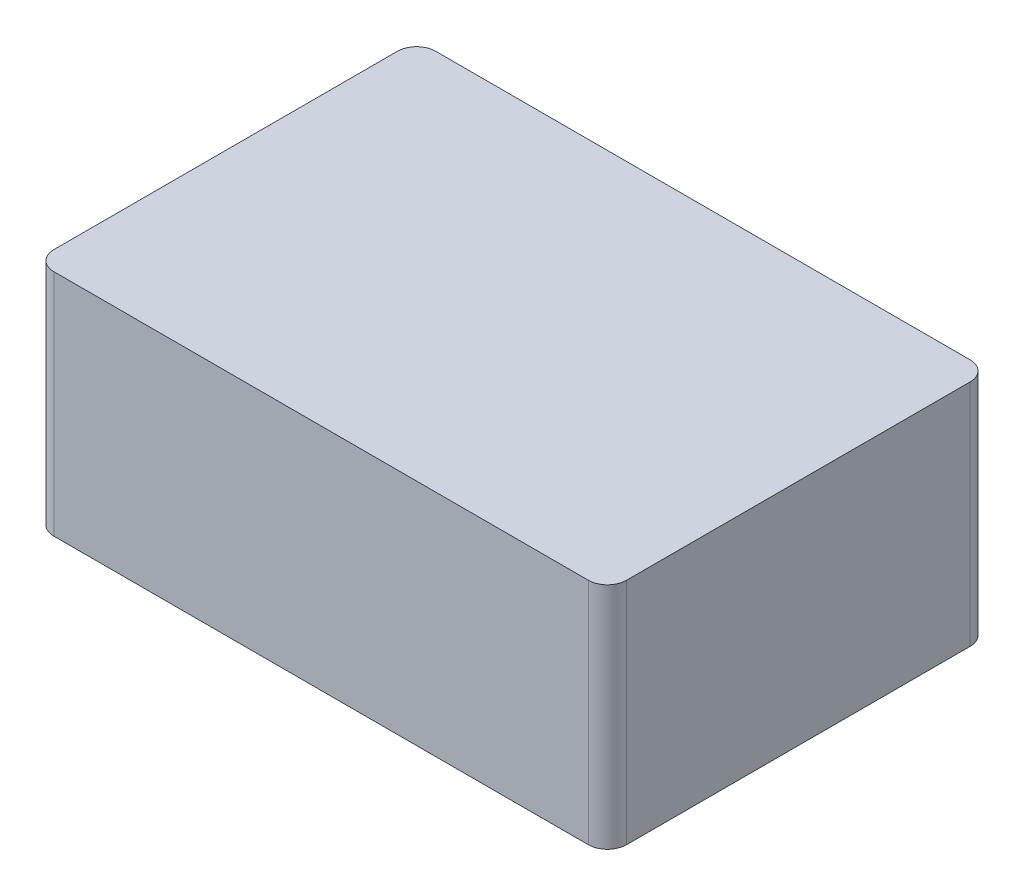
from build123d import *

# Parameters (mm, degrees)
SKETCH1_W               = 150
SKETCH1_H               = 100
BOSS_EXTRUDE1_DEPTH     = 60
SHELL1_T                = -3
SKETCH2_W               = 4
SKETCH2_H               = 4
BOSS_EXTRUDE2_DEPTH     = 20
SKETCH3_R               = 0.85
CUT_EXTRUDE1_DEPTH      = 10
SKETCH4_W               = 51
SKETCH4_H               = 28.5
BOSS_EXTRUDE3_DEPTH     = 57
SKETCH5_W               = 49
SKETCH5_H               = 26.5
CUT_EXTRUDE2_DEPTH      = 17.5
SKETCH6_W               = 7.316020892
SKETCH6_H               = 10.063527081
SKETCH6_W_2             = 9.991581276
SKETCH6_H_2             = 9.876768552
CUT_EXTRUDE3_DEPTH      = 1
RIB1_REACH              = 188.304
SKETCH7_WALLS_W         = 497.226705155
SKETCH7_WALLS_H         = 2
SKETCH7_WALLS_W_2       = 2
SKETCH7_WALLS_H_2       = 447.528019614
SKETCH7_WALLS_H_3       = 446.492630332
SKETCH7_WALLS_H_4       = 428.743099781
SKETCH7_WALLS_W_3       = 498.853745456
SKETCH8_W               = 7
SKETCH8_H               = 7
BOSS_EXTRUDE4_DEPTH     = 57
MIRROR2_COPY_1_SKETCH_W = 7
MIRROR2_COPY_1_SKETCH_H = 7
MIRROR2_COPY_1_DEPTH    = 57
SKETCH9_R               = 2
CUT_EXTRUDE4_DEPTH      = 10
MIRROR4_COPY_1_SKETCH_R = 2
MIRROR4_COPY_1_DEPTH    = 10
FILLET1_R               = 5


with BuildPart() as part:
    # Sketch1 → Boss-Extrude1 (new body)
    with BuildSketch(Plane(origin=(0, 0, 0), x_dir=(1, 0, 0), z_dir=(0, 1, 0))):
        with Locations((75, 50)):
            Rectangle(SKETCH1_W, SKETCH1_H)
    extrude(amount=BOSS_EXTRUDE1_DEPTH)

    # Shell1
    shell1_openings = [part.faces().sort_by_distance(p)[0] for p in [
        (75, 0, -50),
    ]]
    offset(amount=SHELL1_T, openings=shell1_openings, kind=Kind.INTERSECTION)

    # Sketch2 → Boss-Extrude2 (add)
    with BuildSketch(Plane.XZ.offset(-57)):
        with Locations((20, -90)):
            Rectangle(SKETCH2_W, SKETCH2_H)
        with Locations((64.26, -90)):
            Rectangle(SKETCH2_W, SKETCH2_H)
        with Locations((20, -38.12)):
            Rectangle(SKETCH2_W, SKETCH2_H)
        with Locations((64.26, -38.12)):
            Rectangle(SKETCH2_W, SKETCH2_H)
    extrude(amount=BOSS_EXTRUDE2_DEPTH)

    # Sketch3 → Cut-Extrude1 (cut)
    with BuildSketch(Plane.XZ.offset(-37)):
        with Locations(Location((20.3, -89.7, 0), (0, 0, 270))):
            Circle(SKETCH3_R)
        with Locations(Location((20.3, -38.42, 0), (0, 0, 270))):
            Circle(SKETCH3_R)
        with Locations(Location((63.96, -38.42, 0), (0, 0, 270))):
            Circle(SKETCH3_R)
        with Locations(Location((63.96, -89.7, 0), (0, 0, 270))):
            Circle(SKETCH3_R)
    extrude(amount=-CUT_EXTRUDE1_DEPTH, mode=Mode.SUBTRACT)

    # Sketch4 → Boss-Extrude3 (add)
    with BuildSketch(Plane.XZ.offset(-57)):
        with Locations((45.5, -20.25)):
            Rectangle(SKETCH4_W, SKETCH4_H)
    extrude(amount=BOSS_EXTRUDE3_DEPTH)

    # Sketch5 → Cut-Extrude2 (cut)
    with BuildSketch(Plane.XZ):
        with Locations((45.5, -20.25)):
            Rectangle(SKETCH5_W, SKETCH5_H)
    extrude(amount=-CUT_EXTRUDE2_DEPTH, mode=Mode.SUBTRACT)

    # Sketch6 → Cut-Extrude3 (cut)
    with BuildSketch(Plane(origin=(71, 0, 0), x_dir=(0, 0, -1), z_dir=(1, 0, 0))):
        with Locations((27.946274495, 5.031763541)):
            Rectangle(SKETCH6_W, SKETCH6_H)
        with Locations((13.255259514, 4.938384276)):
            Rectangle(SKETCH6_W_2, SKETCH6_H_2)
    extrude(amount=-CUT_EXTRUDE3_DEPTH, mode=Mode.SUBTRACT)

    # Sketch7 walls → Rib1 (add, up to next)
    with BuildSketch(Plane(origin=(0, 47, 0), x_dir=(-1, 0, 0), z_dir=(0, -1, 0)), mode=Mode.PRIVATE) as rib1_sk1:
        with Locations((-74.334392604, 80.691896577)):
            Rectangle(SKETCH7_WALLS_W, SKETCH7_WALLS_H)
    rib1_tool1 = extrude(rib1_sk1.sketch, amount=-RIB1_REACH, mode=Mode.PRIVATE) - part.part
    # Sketch7 walls → Rib1 (add, up to next)
    with BuildSketch(Plane(origin=(0, 47, 0), x_dir=(-1, 0, 0), z_dir=(0, -1, 0)), mode=Mode.PRIVATE) as rib1_sk2:
        with Locations((-75.443738264, 51.479127546)):
            Rectangle(SKETCH7_WALLS_W_2, SKETCH7_WALLS_H_2)
    rib1_tool2 = extrude(rib1_sk2.sketch, amount=-RIB1_REACH, mode=Mode.PRIVATE) - part.part
    # Sketch7 walls → Rib1 (add, up to next)
    with BuildSketch(Plane(origin=(0, 47, 0), x_dir=(-1, 0, 0), z_dir=(0, -1, 0)), mode=Mode.PRIVATE) as rib1_sk3:
        with Locations((-118.338437094, 50.961432905)):
            Rectangle(SKETCH7_WALLS_W_2, SKETCH7_WALLS_H_3)
    rib1_tool3 = extrude(rib1_sk3.sketch, amount=-RIB1_REACH, mode=Mode.PRIVATE) - part.part
    # Sketch7 walls → Rib1 (add, up to next)
    with BuildSketch(Plane(origin=(0, 47, 0), x_dir=(-1, 0, 0), z_dir=(0, -1, 0)), mode=Mode.PRIVATE) as rib1_sk4:
        with Locations((-35.211469016, 65.01314459)):
            Rectangle(SKETCH7_WALLS_W_2, SKETCH7_WALLS_H_4)
    rib1_tool4 = extrude(rib1_sk4.sketch, amount=-RIB1_REACH, mode=Mode.PRIVATE) - part.part
    # Sketch7 walls → Rib1 (add, up to next)
    with BuildSketch(Plane(origin=(0, 47, 0), x_dir=(-1, 0, 0), z_dir=(0, -1, 0)), mode=Mode.PRIVATE) as rib1_sk5:
        with Locations((-73.520872454, 57.173768597)):
            Rectangle(SKETCH7_WALLS_W_3, SKETCH7_WALLS_H)
    rib1_tool5 = extrude(rib1_sk5.sketch, amount=-RIB1_REACH, mode=Mode.PRIVATE) - part.part
    add(rib1_tool1.solids().sort_by_distance((74.334392604, 47, -80.691896577))[0])
    add(rib1_tool2.solids().sort_by_distance((75.443738264, 47, -51.479127546))[0])
    add(rib1_tool3.solids().sort_by_distance((118.338437094, 47, -50.961432905))[0])
    add(rib1_tool4.solids().sort_by_distance((35.211469016, 47, -65.01314459))[0])
    add(rib1_tool5.solids().sort_by_distance((73.520872454, 47, -57.173768597))[0])

    # Sketch8 → Boss-Extrude4 (add)
    with BuildSketch(Plane.XZ.offset(-57)):
        with Locations((6.5, -6.5)):
            Rectangle(SKETCH8_W, SKETCH8_H)
    boss_extrude4 = extrude(amount=BOSS_EXTRUDE4_DEPTH)

    # Mirror1: Boss-Extrude4 across plane
    add(boss_extrude4.mirror(Plane.XY.offset(-50)))

    # Mirror2: Boss-Extrude4 across plane
    add(boss_extrude4.mirror(Plane.ZY.offset(-75)))

    # Mirror2 copy 1 sketch → Mirror2 copy 1 (add)
    with BuildSketch(Plane(origin=(150, 57, -100), x_dir=(-1, 0, 0), z_dir=(0, -1, 0))):
        with Locations((6.5, -6.5)):
            Rectangle(MIRROR2_COPY_1_SKETCH_W, MIRROR2_COPY_1_SKETCH_H)
    extrude(amount=MIRROR2_COPY_1_DEPTH)

    # Sketch9 → Cut-Extrude4 (cut)
    with BuildSketch(Plane.XZ):
        with Locations(Location((5, -5, 0), (0, 0, 270))):
            Circle(SKETCH9_R)
    cut_extrude4 = extrude(amount=-CUT_EXTRUDE4_DEPTH, mode=Mode.SUBTRACT)

    # Mirror3: Cut-Extrude4 across plane
    add(cut_extrude4.mirror(Plane.XY.offset(-50)), mode=Mode.SUBTRACT)

    # Mirror4: Cut-Extrude4 across plane
    add(cut_extrude4.mirror(Plane.ZY.offset(-75)), mode=Mode.SUBTRACT)

    # Mirror4 copy 1 sketch → Mirror4 copy 1 (cut)
    with BuildSketch(Plane(origin=(150, 0, -100), x_dir=(-1, 0, 0), z_dir=(0, -1, 0))):
        with Locations(Location((5, -5, 0), (0, 0, 270))):
            Circle(MIRROR4_COPY_1_SKETCH_R)
    extrude(amount=-MIRROR4_COPY_1_DEPTH, mode=Mode.SUBTRACT)

    # Fillet1
    fillet1_edges = [part.edges().sort_by_distance(p)[0] for p in [
        (0, 30, -100),
        (150, 30, -100),
        (150, 30, 0),
        (0, 30, 0),
    ]]
    fillet(fillet1_edges, radius=FILLET1_R)


solid = part.part
